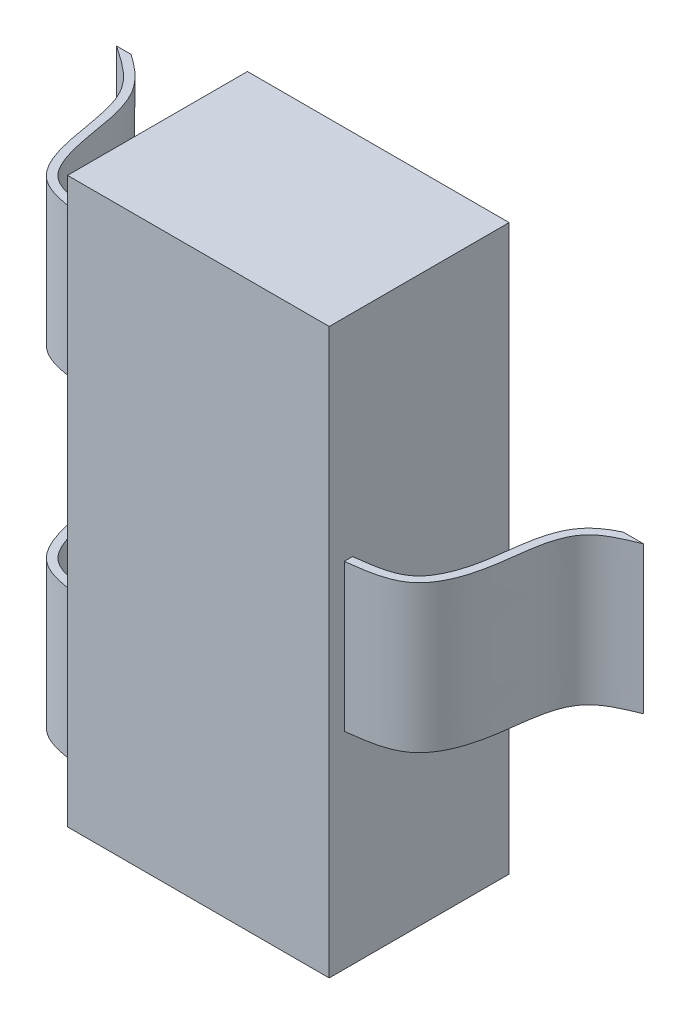
from build123d import *

# Parameters (mm, degrees)
EXTRUDE1_DEPTH     = 1.1
CUT_EXTRUDE1_DEPTH = 4.19
CUT_EXTRUDE2_DEPTH = 4.19


with BuildPart() as part:
    # COMPONENT_OUTLINE → Extrude1 (new body)
    with BuildSketch(Plane.XY):
        Polygon((-0.875, -1.71), (0.725, -1.71), (0.725, -0.45), (1.5475, -0.45), (1.5475, 0.45), (0.725, 0.45), (0.725, 1.74), (-0.875, 1.74), (-0.875, 1.475), (-1.675, 1.475), (-1.675, 0.575), (-0.875, 0.575), (-0.875, -0.55), (-1.675, -0.55), (-1.675, -1.45), (-0.875, -1.45), align=None)
    extrude(amount=EXTRUDE1_DEPTH)

    # Sketch1 → Cut-Extrude1 (cut, through all)
    with BuildSketch(Plane.XZ.offset(1.45)):
        with BuildLine():
            Line((0.725, 1.1), (1.5475, 1.1))
            Line((1.5475, 1.1), (1.5475, 0))
            add(Edge.make_bspline(
                [(0.725, 1.007684008), (0.841255766, 0.993236255), (1.074434419, 0.964257843), (1.240697247, 0.566279231), (1.212102737, 0.136753725), (1.466368993, 0.033080078), (1.5475, 0)],
                knots=[0, 0, 0, 0, 0.228895666, 0.459104825, 0.827411741, 1, 1, 1, 1], degree=3))
            Line((0.725, 1.007684008), (0.725, 1.1))
        make_face()
        with BuildLine():
            Line((-0.875, 1.1), (-0.875, 1.007684008))
            add(Edge.make_bspline(
                [(-0.875, 1.007684008), (-0.992502858, 0.993714751), (-1.247070824, 0.963450589), (-1.342415555, 0.56189323), (-1.384469235, 0.196400416), (-1.584715613, 0.061032749), (-1.675, 0)],
                knots=[0, 0, 0, 0, 0.232825369, 0.504412246, 0.776556075, 1, 1, 1, 1], degree=3))
            Line((-1.675, 0), (-1.675, 1.1))
            Line((-1.675, 1.1), (-0.875, 1.1))
        make_face()
    extrude(amount=-CUT_EXTRUDE1_DEPTH, mode=Mode.SUBTRACT)

    # Sketch2 → Cut-Extrude2 (cut, through all)
    with BuildSketch(Plane.XZ.offset(1.45)):
        with BuildLine():
            Line((0.725, 0), (1.421572568, 0))
            add(Edge.make_bspline(
                [(1.421572568, 0), (1.398439084, 0.011285624), (1.375838095, 0.023644995), (1.327364404, 0.055460599), (1.301887511, 0.076567597), (1.259910489, 0.125534473), (1.243394855, 0.152637933), (1.177610694, 0.294933575), (1.174271294, 0.429683105), (1.134079821, 0.680245939), (1.093633579, 0.798176416), (0.992225356, 0.893756481), (0.949632552, 0.913640339), (0.845445066, 0.941870469), (0.7862927, 0.949660717), (0.725, 0.957298469)],
                knots=[0.07541425, 0.07541425, 0.07541425, 0.07541425, 0.125, 0.125, 0.1875, 0.1875, 0.25, 0.25, 0.5, 0.5, 0.75, 0.75, 0.875, 0.875, 0.995948591, 0.995948591, 0.995948591, 0.995948591], degree=3))
            Line((0.725, 0.957298469), (0.725, 0))
        make_face()
        with BuildLine():
            Line((-1.586416297, 0), (-0.875, 0))
            Line((-0.875, 0), (-0.875, 0.957331048))
            add(Edge.make_bspline(
                [(-1.586416297, 0), (-1.555884998, 0.021384965), (-1.525710826, 0.043709629), (-1.449960416, 0.108153898), (-1.406998869, 0.155193673), (-1.317807524, 0.317989625), (-1.304878373, 0.44302641), (-1.260607801, 0.687731731), (-1.227980141, 0.806351912), (-1.137249482, 0.896473216), (-1.096849985, 0.915474598), (-0.994853528, 0.942624737), (-0.935985962, 0.950060656), (-0.875, 0.957331048)],
                knots=[0.049723417, 0.049723417, 0.049723417, 0.049723417, 0.125, 0.125, 0.25, 0.25, 0.5, 0.5, 0.75, 0.75, 0.875, 0.875, 0.996097337, 0.996097337, 0.996097337, 0.996097337], degree=3))
        make_face()
    extrude(amount=-CUT_EXTRUDE2_DEPTH, mode=Mode.SUBTRACT)


solid = part.part
